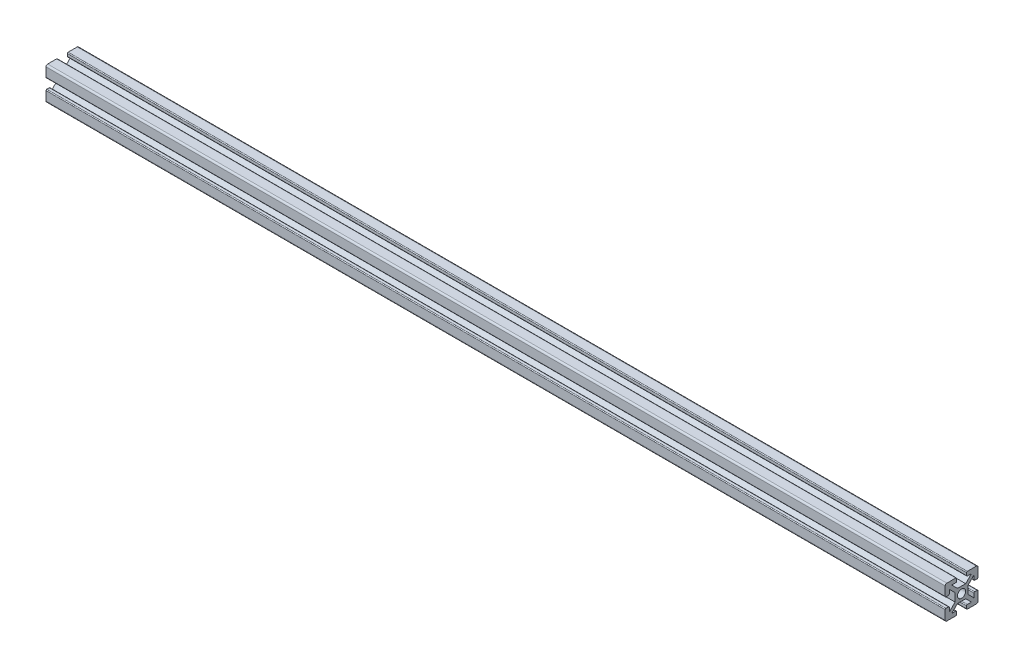
from build123d import *

# Parameters (mm, degrees)
SKETCH11_R                            = 2.5
ALUMINIUM_PROF_ALUMINIUM_PROF_1_DEPTH = 550
SKETCH12_R                            = 2.5
CUT_EXTRUDE1_DEPTH                    = 287.723330349


with BuildPart() as part:
    # Sketch11 → Aluminium prof ALUMINIUM PROF(1) (new body)
    with BuildSketch(Plane.YZ.offset(-263.796296296)):
        with BuildLine():
            Line((-2.5, 4), (2.5, 4))
            Line((2.5, 4), (6.035533906, 7.535533906))
            Line((6.035533906, 7.535533906), (3.535533906, 7.535533906))
            ThreePointArc((3.535533906, 7.535533906), (3.181980515, 7.681980515), (3.035533906, 8.035533906))
            Line((3.035533906, 8.035533906), (3.035533906, 9.535533906))
            ThreePointArc((3.035533906, 9.535533906), (3.181980515, 9.889087297), (3.535533906, 10.035533906))
            Line((3.535533906, 10.035533906), (9.035533906, 10.035533906))
            ThreePointArc((9.035533906, 10.035533906), (9.742640687, 9.742640687), (10.035533906, 9.035533906))
            Line((10.035533906, 9.035533906), (10.035533906, 3.535533906))
            ThreePointArc((10.035533906, 3.535533906), (9.889087297, 3.181980515), (9.535533906, 3.035533906))
            Line((9.535533906, 3.035533906), (8.035533906, 3.035533906))
            ThreePointArc((8.035533906, 3.035533906), (7.681980515, 3.181980515), (7.535533906, 3.535533906))
            Line((7.535533906, 3.535533906), (7.535533906, 6.035533906))
            Line((7.535533906, 6.035533906), (4, 2.5))
            Line((4, 2.5), (4, -2.5))
            Line((4, -2.5), (7.535533906, -6.035533906))
            Line((7.535533906, -6.035533906), (7.535533906, -3.535533906))
            ThreePointArc((7.535533906, -3.535533906), (7.681980515, -3.181980515), (8.035533906, -3.035533906))
            Line((8.035533906, -3.035533906), (9.535533906, -3.035533906))
            ThreePointArc((9.535533906, -3.035533906), (9.889087297, -3.181980515), (10.035533906, -3.535533906))
            Line((10.035533906, -3.535533906), (10.035533906, -9.035533906))
            ThreePointArc((10.035533906, -9.035533906), (9.742640687, -9.742640687), (9.035533906, -10.035533906))
            Line((9.035533906, -10.035533906), (3.535533906, -10.035533906))
            ThreePointArc((3.535533906, -10.035533906), (3.181980515, -9.889087297), (3.035533906, -9.535533906))
            Line((3.035533906, -9.535533906), (3.035533906, -8.035533906))
            ThreePointArc((3.035533906, -8.035533906), (3.181980515, -7.681980515), (3.535533906, -7.535533906))
            Line((3.535533906, -7.535533906), (6.035533906, -7.535533906))
            Line((6.035533906, -7.535533906), (2.5, -4))
            Line((2.5, -4), (-2.5, -4))
            Line((-2.5, -4), (-6.035533906, -7.535533906))
            Line((-6.035533906, -7.535533906), (-3.535533906, -7.535533906))
            ThreePointArc((-3.535533906, -7.535533906), (-3.181980515, -7.681980515), (-3.035533906, -8.035533906))
            Line((-3.035533906, -8.035533906), (-3.035533906, -9.535533906))
            ThreePointArc((-3.035533906, -9.535533906), (-3.181980515, -9.889087297), (-3.535533906, -10.035533906))
            Line((-3.535533906, -10.035533906), (-9.035533906, -10.035533906))
            ThreePointArc((-9.035533906, -10.035533906), (-9.742640687, -9.742640687), (-10.035533906, -9.035533906))
            Line((-10.035533906, -9.035533906), (-10.035533906, -3.535533906))
            ThreePointArc((-10.035533906, -3.535533906), (-9.889087297, -3.181980515), (-9.535533906, -3.035533906))
            Line((-9.535533906, -3.035533906), (-8.035533906, -3.035533906))
            ThreePointArc((-8.035533906, -3.035533906), (-7.681980515, -3.181980515), (-7.535533906, -3.535533906))
            Line((-7.535533906, -3.535533906), (-7.535533906, -6.035533906))
            Line((-7.535533906, -6.035533906), (-4, -2.5))
            Line((-4, -2.5), (-4, 2.5))
            Line((-4, 2.5), (-7.535533906, 6.035533906))
            Line((-7.535533906, 6.035533906), (-7.535533906, 3.535533906))
            ThreePointArc((-7.535533906, 3.535533906), (-7.681980515, 3.181980515), (-8.035533906, 3.035533906))
            Line((-8.035533906, 3.035533906), (-9.535533906, 3.035533906))
            ThreePointArc((-9.535533906, 3.035533906), (-9.889087297, 3.181980515), (-10.035533906, 3.535533906))
            Line((-10.035533906, 3.535533906), (-10.035533906, 9.035533906))
            ThreePointArc((-10.035533906, 9.035533906), (-9.742640687, 9.742640687), (-9.035533906, 10.035533906))
            Line((-9.035533906, 10.035533906), (-3.535533906, 10.035533906))
            ThreePointArc((-3.535533906, 10.035533906), (-3.181980515, 9.889087297), (-3.035533906, 9.535533906))
            Line((-3.035533906, 9.535533906), (-3.035533906, 8.035533906))
            ThreePointArc((-3.035533906, 8.035533906), (-3.181980515, 7.681980515), (-3.535533906, 7.535533906))
            Line((-3.535533906, 7.535533906), (-6.035533906, 7.535533906))
            Line((-6.035533906, 7.535533906), (-2.5, 4))
        make_face()
        Circle(SKETCH11_R, mode=Mode.SUBTRACT)
    extrude(amount=ALUMINIUM_PROF_ALUMINIUM_PROF_1_DEPTH)

    # Sketch12 → Cut-Extrude1 (cut, through all)
    with BuildSketch(Plane(origin=(0, 4, 0), x_dir=(1, 0, 0), z_dir=(0, 1, 0))):
        with Locations(Location((-248.796296296, 0, 0), (0, 0, 270))):
            Circle(SKETCH12_R)
        with Locations(Location((271.203703704, 0, 0), (0, 0, 270))):
            Circle(SKETCH12_R)
    extrude(amount=-CUT_EXTRUDE1_DEPTH, mode=Mode.SUBTRACT)


solid = part.part
